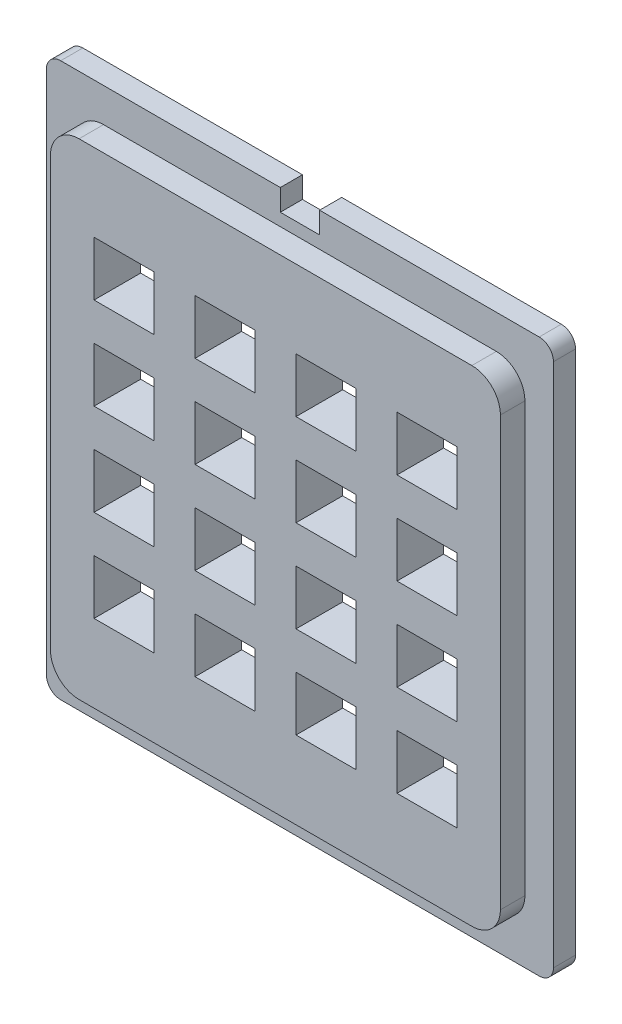
from build123d import *

# Parameters (mm, degrees)
BASE_DEPTH        = 3.0988
SKETCH4_R         = 1.016
MOUNT_HOLES_DEPTH = 4.0988
EXTRUDE2_DEPTH    = 3.429
SKETCH3_W         = 8.382
SKETCH3_H         = 7.62
KEY_DEPTH         = 7.5278
KEYS_COUNT        = 4
KEYS_PITCH        = 14.14018
KEYS_COUNT_DIR2   = 4
KEYS_PITCH_DIR2   = 12.869418


with BuildPart() as part:
    # Sketch1 → base (new body)
    with BuildSketch(Plane.XY):
        with BuildLine():
            Line((-2.75, 38.75), (-33.5, 38.75))
            ThreePointArc((-33.5, 38.75), (-34.914213562, 38.164213562), (-35.5, 36.75))
            Line((-35.5, 36.75), (-35.5, -36.75))
            ThreePointArc((-35.5, -36.75), (-34.914213562, -38.164213562), (-33.5, -38.75))
            Line((-33.5, -38.75), (33.5, -38.75))
            ThreePointArc((33.5, -38.75), (34.914213562, -38.164213562), (35.5, -36.75))
            Line((35.5, -36.75), (35.5, 36.75))
            ThreePointArc((35.5, 36.75), (34.914213562, 38.164213562), (33.5, 38.75))
            Line((33.5, 38.75), (2.75, 38.75))
            Line((2.75, 38.75), (2.75, 35.75))
            Line((2.75, 35.75), (-2.75, 35.75))
            Line((-2.75, 35.75), (-2.75, 38.75))
        make_face()
    extrude(amount=BASE_DEPTH)

    # Sketch4 → mount holes (cut, through all)
    with BuildSketch(Plane.XY.offset(3.0988)):
        with Locations((-30, 29.5)):
            Circle(SKETCH4_R)
        with Locations((30, 29.5)):
            Circle(SKETCH4_R)
        with Locations((30, -29.5)):
            Circle(SKETCH4_R)
        with Locations((-30, -29.5)):
            Circle(SKETCH4_R)
    extrude(amount=-MOUNT_HOLES_DEPTH, mode=Mode.SUBTRACT)

    # Sketch2 → Extrude2 (add)
    with BuildSketch(Plane.XY.offset(3.0988)):
        with BuildLine():
            Line((-27.5, 34), (27.5, 34))
            ThreePointArc((27.5, 34), (30.328427125, 32.828427125), (31.5, 30))
            Line((31.5, 30), (31.5, -30))
            ThreePointArc((31.5, -30), (30.328427125, -32.828427125), (27.5, -34))
            Line((27.5, -34), (-27.5, -34))
            ThreePointArc((-27.5, -34), (-30.328427125, -32.828427125), (-31.5, -30))
            Line((-31.5, -30), (-31.5, 30))
            ThreePointArc((-31.5, 30), (-30.328427125, 32.828427125), (-27.5, 34))
        make_face()
    extrude(amount=EXTRUDE2_DEPTH)

    # Sketch3 → key (cut, through all)
    with BuildSketch(Plane.XY.offset(6.5278)):
        with Locations((-21.209, 19.304)):
            Rectangle(SKETCH3_W, SKETCH3_H)
    key = extrude(amount=-KEY_DEPTH, mode=Mode.SUBTRACT)

    # keys: key 4 × 4
    with Locations(*[(i * KEYS_PITCH, -j * KEYS_PITCH_DIR2, 0) for i in range(KEYS_COUNT) for j in range(KEYS_COUNT_DIR2) if (i, j) != (0, 0)]):
        add(key, mode=Mode.SUBTRACT)


solid = part.part
